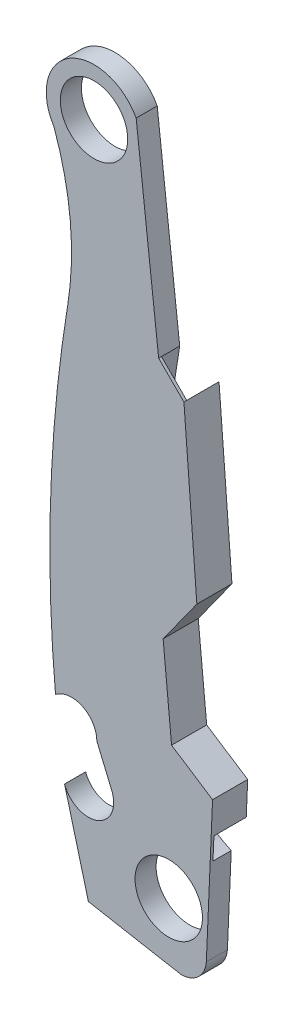
from build123d import *

# Parameters (mm, degrees)
SKETCH1_R           = 3.048
BOSS_EXTRUDE1_DEPTH = 1.905
CUT_EXTRUDE2_DEPTH  = 1.651
BOSS_EXTRUDE3_DEPTH = 1.27


with BuildPart() as part:
    # Sketch1 → Boss-Extrude1 (new body)
    with BuildSketch(Plane.XY):
        with BuildLine():
            Line((-13.231934716, 13.729837747), (-15.263934716, 31.509837747))
            ThreePointArc((-15.263934716, 31.509837747), (-21.261976505, 33.200417113), (-22.702706225, 27.137508425))
            ThreePointArc((-22.702706225, 27.137508425), (-21.220829792, 20.52075151), (-21.455464715, 13.744146439))
            ThreePointArc((-21.455464715, 13.744146439), (-22.988481312, -1.727276666), (-22.555391654, -17.268431904))
            ThreePointArc((-22.555391654, -17.268431904), (-20.128095916, -16.969854608), (-18.819934716, -19.036162253))
            Line((-18.819934716, -19.036162253), (-17.534121248, -22.084162253))
            ThreePointArc((-17.534121248, -22.084162253), (-18.691312873, -25.205533652), (-21.737196185, -23.862162253))
            Line((-21.737196185, -23.862162253), (-19.581934716, -31.990162253))
            ThreePointArc((-19.581934716, -31.990162253), (-15.392244863, -32.759368057), (-11.199934716, -33.514162253))
            ThreePointArc((-11.199934716, -33.514162253), (-9.63879843, -32.898087249), (-8.919111875, -31.38192559))
            Line((-8.919111875, -31.38192559), (-8.355134716, -18.401162253))
            Line((-8.355134716, -18.401162253), (-12.063534716, -15.988162253))
            Line((-12.063534716, -15.988162253), (-12.825534716, -8.037962253))
            Line((-12.825534716, -8.037962253), (-9.777534716, -3.796162253))
            Line((-9.777534716, -3.796162253), (-10.945934716, 11.443837747))
            Line((-10.945934716, 11.443837747), (-13.231934716, 13.729837747))
        make_face()
        with Locations((-19.073934716, 29.477837747)):
            Circle(SKETCH1_R, mode=Mode.SUBTRACT)
        with Locations((-12.317534716, -28.103962253)):
            Circle(SKETCH1_R, mode=Mode.SUBTRACT)
    extrude(amount=BOSS_EXTRUDE1_DEPTH)

    # Sketch7 → Cut-Extrude2 (cut)
    with BuildSketch(Plane.XY):
        with BuildLine():
            Line((-10.945934716, 11.443837747), (-13.231934716, 13.729837747))
            ThreePointArc((-13.231934716, 13.729837747), (-14.796876411, 3.164765256), (-16.025932156, -7.444627811))
            ThreePointArc((-16.025932156, -7.444627811), (-14.913011554, -14.738413577), (-11.669461291, -21.365425329))
            ThreePointArc((-11.669461291, -21.365425329), (-10.207206492, -22.532020863), (-8.57425285, -23.444488198))
            Line((-8.57425285, -23.444488198), (-8.486546668, -21.42580149))
            ThreePointArc((-8.486546668, -21.42580149), (-11.247875767, -18.756621385), (-12.886743333, -15.283355784))
            ThreePointArc((-12.886743333, -15.283355784), (-13.652704618, -9.554942708), (-13.628126313, -3.775599409))
            ThreePointArc((-13.628126313, -3.775599409), (-12.336996698, 3.84292494), (-10.945934716, 11.443837747))
        make_face()
    extrude(amount=CUT_EXTRUDE2_DEPTH, mode=Mode.SUBTRACT)

    # Sketch8 → Boss-Extrude3 (add)
    with BuildSketch(Plane(origin=(0, 0, 0), x_dir=(-1, 0, 0), z_dir=(0, 0, -1))):
        with BuildLine():
            Line((8.355134716, -18.401162253), (8.486546668, -21.42580149))
            ThreePointArc((8.486546668, -21.42580149), (11.247875767, -18.756621385), (12.886743333, -15.283355784))
            ThreePointArc((12.886743333, -15.283355784), (13.652704618, -9.554942708), (13.628126313, -3.775599409))
            ThreePointArc((13.628126313, -3.775599409), (12.336996698, 3.84292494), (10.945934716, 11.443837747))
            Line((10.945934716, 11.443837747), (9.777534716, -3.796162253))
            Line((9.777534716, -3.796162253), (12.825534716, -8.037962253))
            Line((12.825534716, -8.037962253), (12.063534716, -15.988162253))
            Line((12.063534716, -15.988162253), (8.355134716, -18.401162253))
        make_face()
    extrude(amount=BOSS_EXTRUDE3_DEPTH)


solid = part.part
